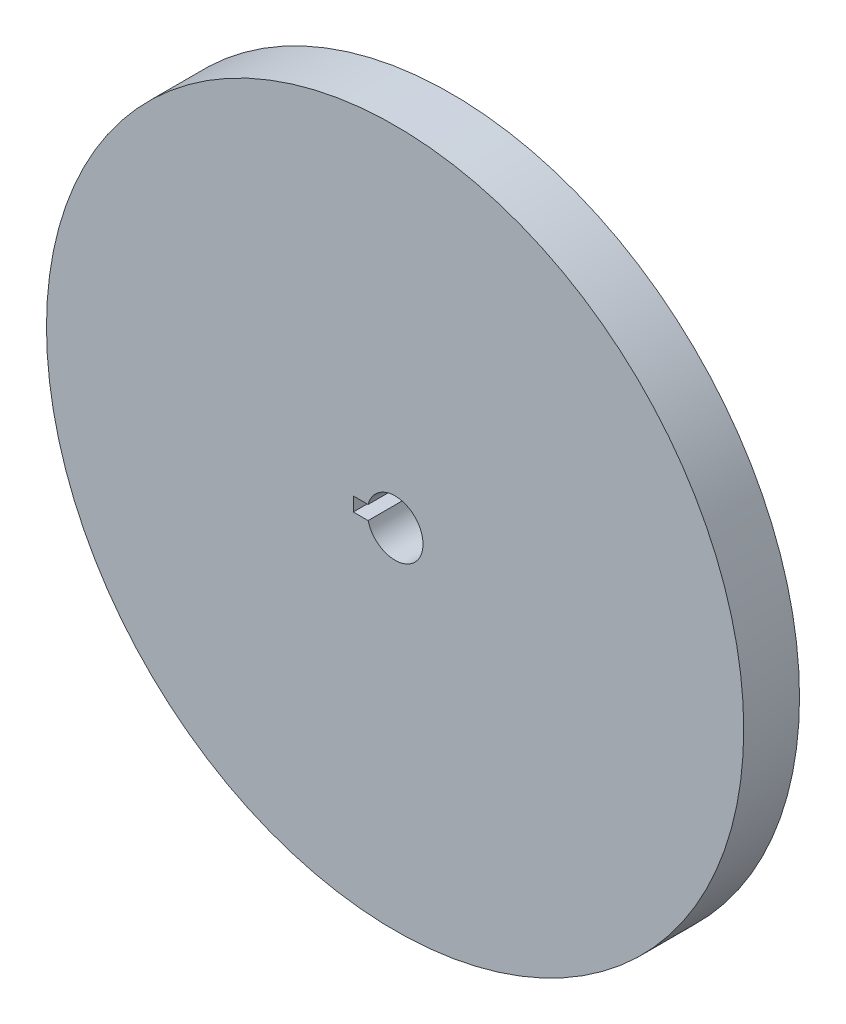
from build123d import *

# Parameters (mm, degrees)
SKETCH1_R           = 125
BOSS_EXTRUDE1_DEPTH = 20
CUT_EXTRUDE1_DEPTH  = 21


with BuildPart() as part:
    # Sketch1 → Boss-Extrude1 (new body)
    with BuildSketch(Plane.XY):
        Circle(SKETCH1_R)
    extrude(amount=BOSS_EXTRUDE1_DEPTH)

    # Sketch2 → Cut-Extrude1 (cut, through all)
    with BuildSketch(Plane.XY.offset(20)):
        with BuildLine():
            Line((-9.682458366, 2.5), (-15, 2.5))
            Line((-15, 2.5), (-15, -2.5))
            Line((-15, -2.5), (-9.682458366, -2.5))
            ThreePointArc((-9.682458366, -2.5), (10, 0), (-9.682458366, 2.5))
        make_face()
    extrude(amount=-CUT_EXTRUDE1_DEPTH, mode=Mode.SUBTRACT)


solid = part.part
